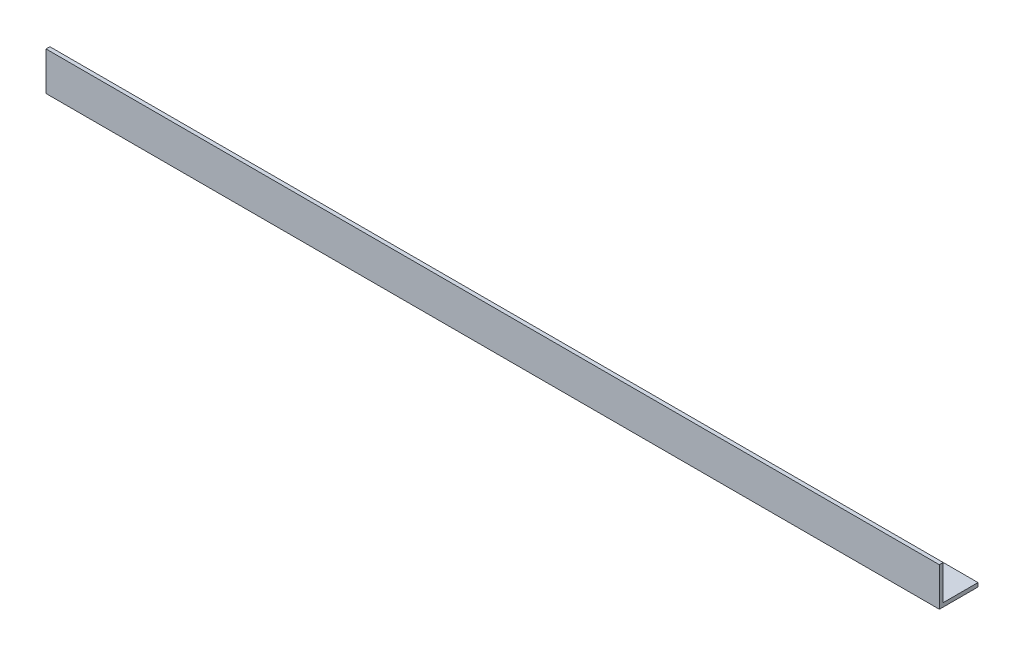
from build123d import *

# Parameters (mm, degrees)
EXTRUDE_1_DEPTH = 347


with BuildPart() as part:
    # Эскиз1 → Бобышка-Вытянуть1 (new body)
    with BuildSketch(Plane(origin=(0, 0, 0), x_dir=(0, 0, -1), z_dir=(1, 0, 0))):
        Polygon((0, 0), (0, 15), (1.5, 15), (1.5, 1.5), (15, 1.5), (15, 0), align=None)
    extrude(amount=EXTRUDE_1_DEPTH)


solid = part.part
